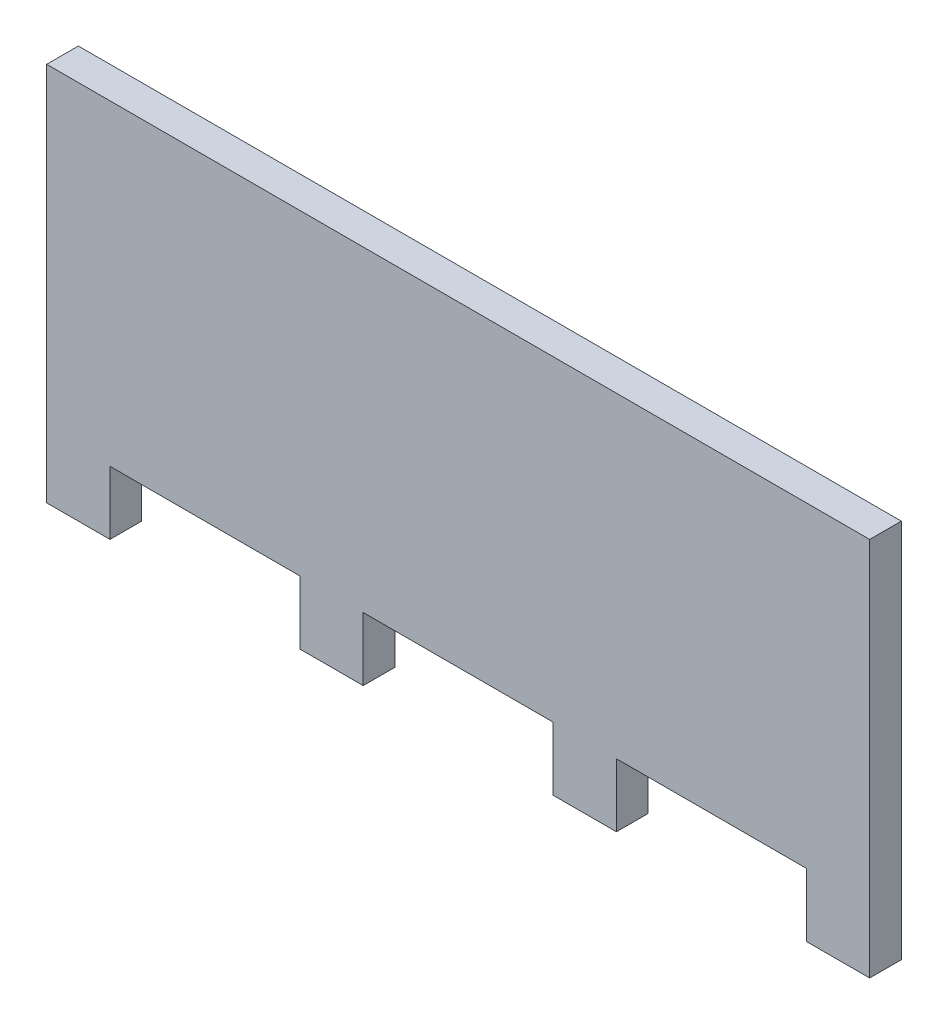
from build123d import *

# Parameters (mm, degrees)
ESQUISSE1_W                = 130
ESQUISSE1_H                = 50
BOSS_EXTRU_1_DEPTH         = 5
ESQUISSE2_W                = 10
ESQUISSE2_H                = 10
BOSS_EXTRU_2_DEPTH         = 5
R_P_TITION_LIN_AIRE1_COUNT = 4
R_P_TITION_LIN_AIRE1_PITCH = 40


with BuildPart() as part:
    # Esquisse1 → Boss.-Extru.1 (new body)
    with BuildSketch(Plane.XY):
        with Locations((0, -12.5)):
            Rectangle(ESQUISSE1_W, ESQUISSE1_H)
    extrude(amount=BOSS_EXTRU_1_DEPTH)

    # Esquisse2 → Boss.-Extru.2 (add)
    with BuildSketch(Plane.XY.offset(5)):
        with Locations((-60, -42.5)):
            Rectangle(ESQUISSE2_W, ESQUISSE2_H)
    boss_extru_2 = extrude(amount=-BOSS_EXTRU_2_DEPTH)

    # Répétition linéaire1: Boss.-Extru.2 ×4
    with Locations(*[(i * R_P_TITION_LIN_AIRE1_PITCH, 0, 0) for i in range(1, R_P_TITION_LIN_AIRE1_COUNT)]):
        add(boss_extru_2)


solid = part.part
